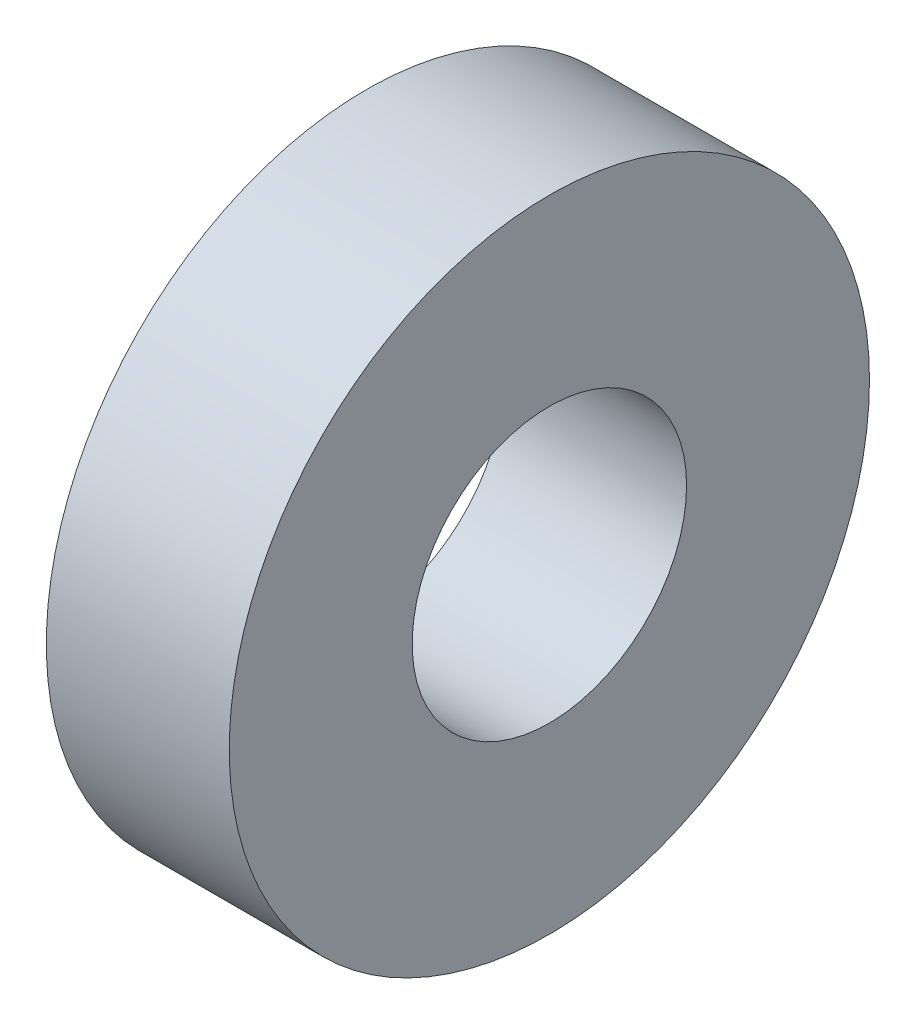
from build123d import *

# Parameters (mm, degrees)
SKETCH1_R           = 14
SKETCH1_R_2         = 6
BOSS_EXTRUDE1_DEPTH = 8


with BuildPart() as part:
    # Sketch1 → Boss-Extrude1 (new body)
    with BuildSketch(Plane(origin=(0, 0, 0), x_dir=(0, 0, -1), z_dir=(1, 0, 0))):
        Circle(SKETCH1_R)
        Circle(SKETCH1_R_2, mode=Mode.SUBTRACT)
    extrude(amount=BOSS_EXTRUDE1_DEPTH)


solid = part.part
